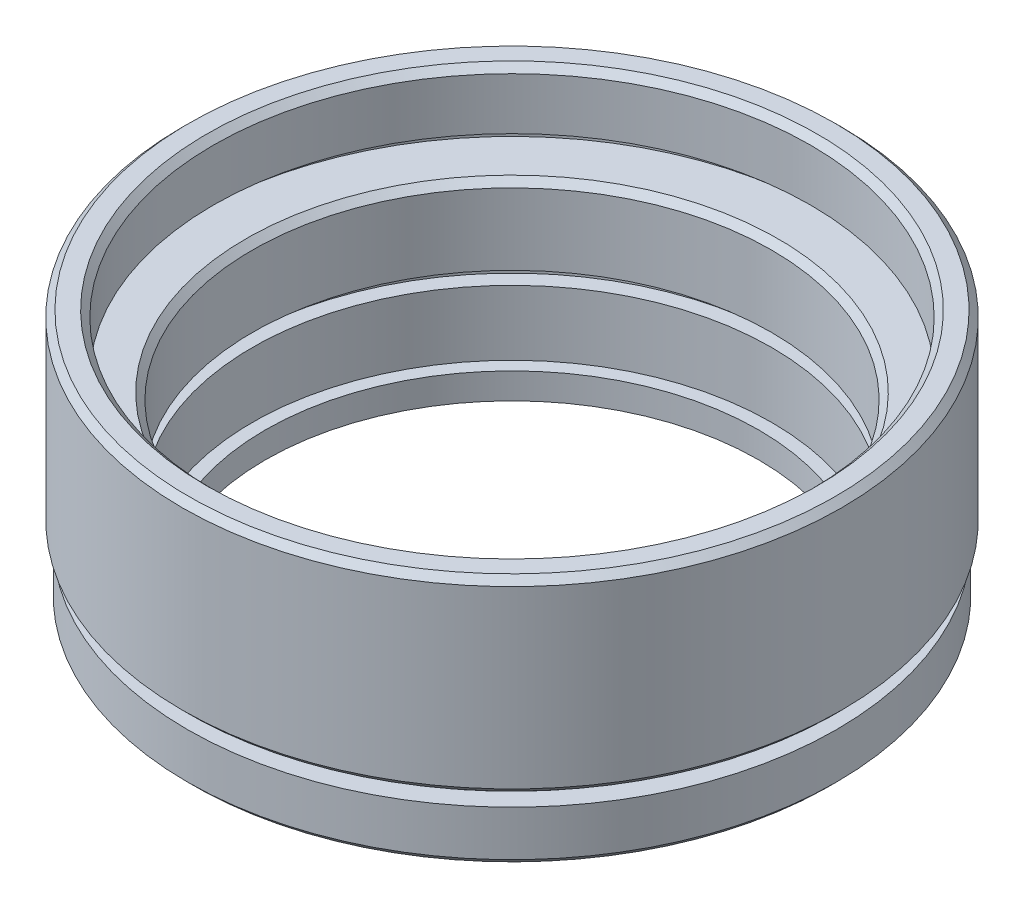
from build123d import *

# Parameters (mm, degrees)
CHAMFER_1_SIZE = 0.5


with BuildPart() as part:
    # 草图1 → 旋转1 (revolve)
    with BuildSketch(Plane.XY, mode=Mode.PRIVATE) as revolve_1_sk:
        Polygon((19, 0), (19, 2), (20, 2), (20, 7), (21.15, 7), (21.15, 8), (20, 8), (20, 14), (24.15, 14), (24.15, 15), (23, 15), (23, 19.5), (24.9, 19.5), (25.4, 19), (25.4, 5.5), (24.9, 5), (23.5, 5), (23.5, 4), (25, 4), (25, 0.5), (24.5, 0), align=None)
    revolve(revolve_1_sk.sketch.rotate(Axis((0, 0, 0), (0, 1, 0)), 90), axis=Axis((0, 0, 0), (0, 1, 0)))  # turned: the seam where the file's is

    # 倒角1
    chamfer_1_edges = [part.edges().sort_by_distance(p)[0] for p in [
        (0, 14, 20),
        (0, 19.5, 23),
    ]]
    chamfer(chamfer_1_edges, length=CHAMFER_1_SIZE)


solid = part.part
